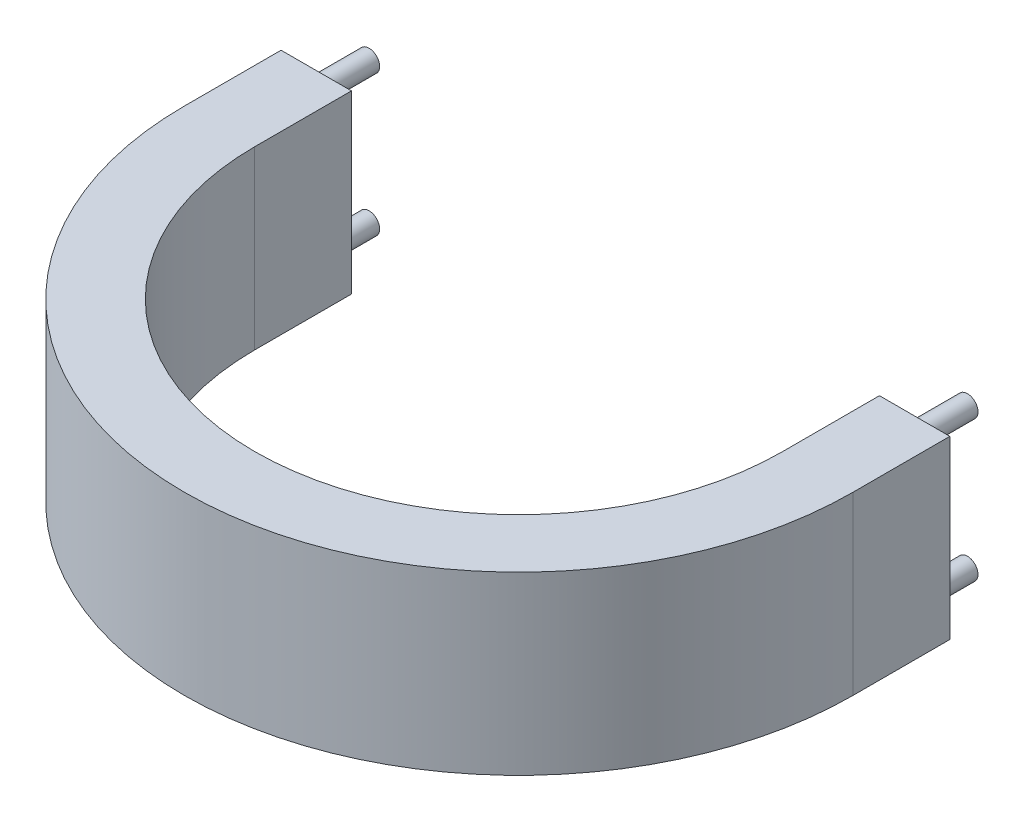
from build123d import *

# Parameters (mm, degrees)
EXTRUDE_1_DEPTH = 20
SKETCH_3_R      = 1.2
EXTRUDE_2_DEPTH = 6


with BuildPart() as part:
    # 草图2 → 凸台-拉伸1 (new body)
    with BuildSketch(Plane(origin=(0, 0, 0), x_dir=(1, 0, 0), z_dir=(0, 1, 0))):
        with BuildLine():
            Line((-30, 0), (-30, 11))
            Line((-30, 11), (-38, 11))
            Line((-38, 11), (-38, 0))
            ThreePointArc((-38, 0), (0, -38), (38, 0))
            Line((38, 0), (38, 11))
            Line((38, 11), (30, 11))
            Line((30, 11), (30, 0))
            ThreePointArc((30, 0), (0, -30), (-30, 0))
        make_face()
    extrude(amount=EXTRUDE_1_DEPTH)

    # 草图3 → 凸台-拉伸2 (add)
    with BuildSketch(Plane(origin=(0, 0, -11), x_dir=(-1, 0, 0), z_dir=(0, 0, -1))):
        with Locations((-34, 18)):
            Circle(SKETCH_3_R)
        with Locations((-34, 2)):
            Circle(SKETCH_3_R)
        with Locations((34, 18)):
            Circle(SKETCH_3_R)
        with Locations((34, 2)):
            Circle(SKETCH_3_R)
    extrude(amount=EXTRUDE_2_DEPTH)


solid = part.part
